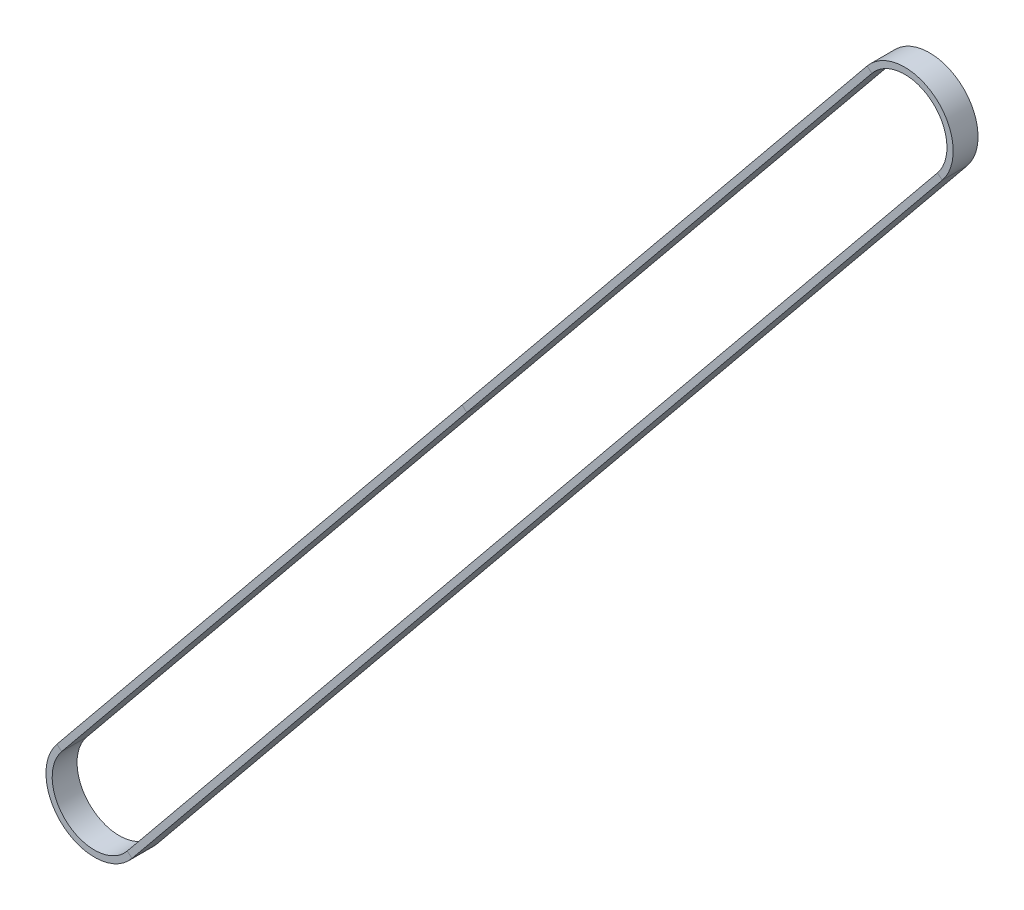
from build123d import *

# Parameters (mm, degrees)
SKETCH2_W = 1.5
SKETCH2_H = 6


with BuildPart() as part:
    # Sweep1: sweep along a path in Sketch1
    with BuildLine(Plane.XY) as sweep1_path:
        Line((187.586551529, 245.900362982), (-7.901243443, 6.450608657))
        ThreePointArc((-7.901243443, 6.450608657), (-6.450608657, -7.901243443), (7.901243443, -6.450608657))
        Line((7.901243443, -6.450608657), (203.389038415, 232.999145667))
        ThreePointArc((203.389038415, 232.999145667), (201.938403629, 247.350997768), (187.586551529, 245.900362982))
    # Sketch2 → Sweep1 (sweep)
    with BuildSketch(Plane(origin=(89.842654043, 126.17548582, 0), x_dir=(-0.77463171, 0.632412613, 0), z_dir=(-0.632412613, -0.77463171, 0))):
        with Locations((0.75, 0)):
            Rectangle(SKETCH2_W, SKETCH2_H)
    sweep(path=sweep1_path.line)


solid = part.part
